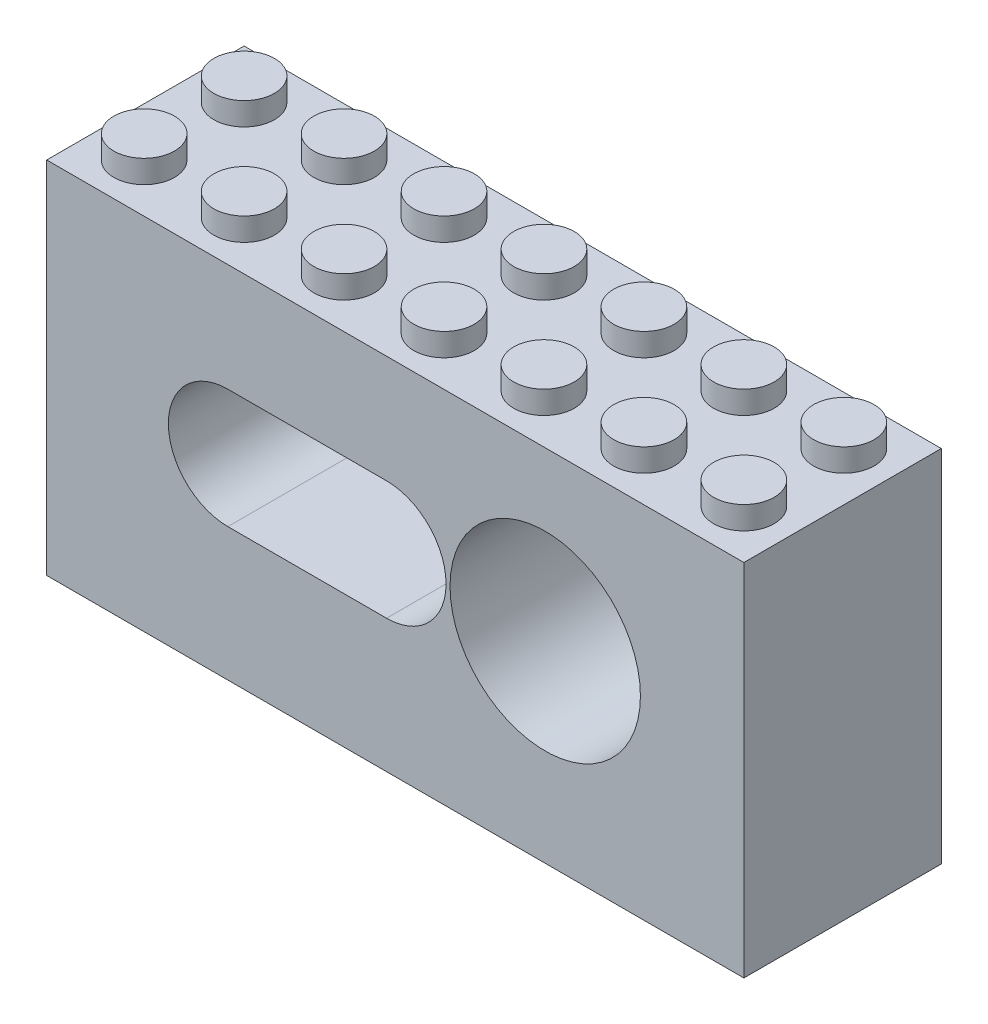
from build123d import *

# Parameters (mm, degrees)
SKETCH1_W           = 55.8
SKETCH1_H           = 15.8
BOSS_EXTRUDE1_DEPTH = 28.8
SKETCH2_R           = 7.62
CUT_EXTRUDE1_DEPTH  = 12.7
SKETCH4_R           = 2.778125
SKETCH4_R_2         = 1.8415
CUT_EXTRUDE2_DEPTH  = 12.7
CUT_EXTRUDE6_DEPTH  = 1.905
SKETCH6_R           = 2.425
BOSS_EXTRUDE2_DEPTH = 1.83
SKETCH7_W           = 53.36
SKETCH7_H           = 13.36
SKETCH7_R           = 3.2625
CUT_EXTRUDE7_DEPTH  = 3


with BuildPart() as part:
    # Sketch1 → Boss-Extrude1 (new body)
    with BuildSketch(Plane(origin=(0, 0, 0), x_dir=(1, 0, 0), z_dir=(0, 1, 0))):
        with Locations((-11.199948696, 8.193463303)):
            Rectangle(SKETCH1_W, SKETCH1_H)
    extrude(amount=BOSS_EXTRUDE1_DEPTH)

    # Sketch2 → Cut-Extrude1 (cut)
    with BuildSketch(Plane.XY.offset(-0.293463303)):
        with Locations((0.800051304, 15.4)):
            Circle(SKETCH2_R)
        with BuildLine():
            Line((-11.899948696, 10.6375), (-24.599948696, 10.6375))
            ThreePointArc((-24.599948696, 10.6375), (-29.362448696, 15.4), (-24.599948696, 20.1625))
            Line((-24.599948696, 20.1625), (-11.899948696, 20.1625))
            ThreePointArc((-11.899948696, 20.1625), (-7.137448696, 15.4), (-11.899948696, 10.6375))
        make_face()
    extrude(amount=-CUT_EXTRUDE1_DEPTH, mode=Mode.SUBTRACT)

    # Sketch4 → Cut-Extrude2 (cut)
    with BuildSketch(Plane(origin=(0, 0, -16.093463303), x_dir=(-1, 0, 0), z_dir=(0, 0, -1))):
        with Locations((-0.800051304, 15.4)):
            Circle(SKETCH4_R)
        with Locations((11.899948696, 15.4)):
            Circle(SKETCH4_R_2)
        with Locations((24.599948696, 15.4)):
            Circle(SKETCH4_R_2)
    extrude(amount=-CUT_EXTRUDE2_DEPTH, mode=Mode.SUBTRACT)

    # Sketch5 → Cut-Extrude6 (cut)
    with BuildSketch(Plane(origin=(0, 0, -16.093463303), x_dir=(-1, 0, 0), z_dir=(0, 0, -1))):
        with BuildLine():
            Line((24.599948696, 20.1625), (11.899948696, 20.1625))
            ThreePointArc((11.899948696, 20.1625), (7.137448696, 15.4), (11.899948696, 10.6375))
            Line((11.899948696, 10.6375), (24.599948696, 10.6375))
            ThreePointArc((24.599948696, 10.6375), (29.362448696, 15.4), (24.599948696, 20.1625))
        make_face()
    extrude(amount=-CUT_EXTRUDE6_DEPTH, mode=Mode.SUBTRACT)

    # Sketch6 → Boss-Extrude2 (add)
    with BuildSketch(Plane(origin=(0, 28.8, 0), x_dir=(1, 0, 0), z_dir=(0, 1, 0))):
        with Locations((12.800051304, 12.193463303)):
            Circle(SKETCH6_R)
        with Locations((12.800051304, 4.193463303)):
            Circle(SKETCH6_R)
        with Locations((4.800051304, 12.193463303)):
            Circle(SKETCH6_R)
        with Locations((4.800051304, 4.193463303)):
            Circle(SKETCH6_R)
        with Locations((-3.199948696, 12.193463303)):
            Circle(SKETCH6_R)
        with Locations((-3.199948696, 4.193463303)):
            Circle(SKETCH6_R)
        with Locations((-11.199948696, 12.193463303)):
            Circle(SKETCH6_R)
        with Locations((-11.199948696, 4.193463303)):
            Circle(SKETCH6_R)
        with Locations((-19.199948696, 12.193463303)):
            Circle(SKETCH6_R)
        with Locations((-19.199948696, 4.193463303)):
            Circle(SKETCH6_R)
        with Locations((-27.199948696, 12.193463303)):
            Circle(SKETCH6_R)
        with Locations((-27.199948696, 4.193463303)):
            Circle(SKETCH6_R)
        with Locations((-35.199948696, 12.193463303)):
            Circle(SKETCH6_R)
        with Locations((-35.199948696, 4.193463303)):
            Circle(SKETCH6_R)
    extrude(amount=BOSS_EXTRUDE2_DEPTH)

    # Sketch7 → Cut-Extrude7 (cut)
    with BuildSketch(Plane.XZ):
        with Locations((-11.199948696, -8.193463303)):
            Rectangle(SKETCH7_W, SKETCH7_H)
        with Locations((8.800051304, -8.193463303)):
            Circle(SKETCH7_R, mode=Mode.SUBTRACT)
        with Locations((0.800051304, -8.193463303)):
            Circle(SKETCH7_R, mode=Mode.SUBTRACT)
        with Locations((-7.199948696, -8.193463303)):
            Circle(SKETCH7_R, mode=Mode.SUBTRACT)
        with Locations((-15.199948696, -8.193463303)):
            Circle(SKETCH7_R, mode=Mode.SUBTRACT)
        with Locations((-23.199948696, -8.193463303)):
            Circle(SKETCH7_R, mode=Mode.SUBTRACT)
        with Locations((-31.199948696, -8.193463303)):
            Circle(SKETCH7_R, mode=Mode.SUBTRACT)
    extrude(amount=-CUT_EXTRUDE7_DEPTH, mode=Mode.SUBTRACT)


solid = part.part
